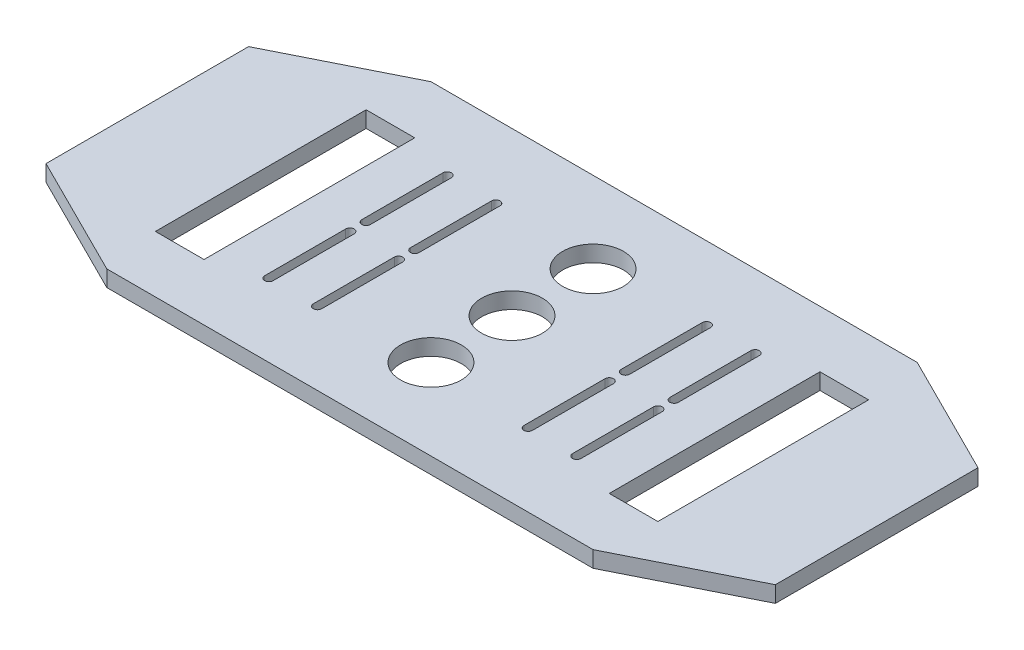
from build123d import *

# Parameters (mm, degrees)
ESQUISSE1_W             = 180
ESQUISSE1_H             = 80
BOSS_EXTRU_1_DEPTH      = 4
ENL_V_MAT_EXTRU_2_DEPTH = 4
ENL_V_MAT_EXTRU_3_DEPTH = 4
ENL_V_MAT_EXTRU_4_REACH = 6
ESQUISSE8_W             = 12
ESQUISSE8_H             = 52
ENL_V_MAT_EXTRU_5_REACH = 6
ESQUISSE9_R             = 7.5


with BuildPart() as part:
    # Esquisse1 → Boss.-Extru.1 (new body)
    with BuildSketch(Plane(origin=(0, 0, 0), x_dir=(1, 0, 0), z_dir=(0, 1, 0))):
        with Locations((90, 40)):
            Rectangle(ESQUISSE1_W, ESQUISSE1_H)
    extrude(amount=BOSS_EXTRU_1_DEPTH)

    # Esquisse2 → Enlèv. mat.-Extru.2 (cut)
    with BuildSketch(Plane(origin=(0, 4, 0), x_dir=(1, 0, 0), z_dir=(0, 1, 0))):
        Polygon((0, 65), (30, 80), (0, 80), align=None)
        Polygon((150, 80), (180, 65), (180, 80), align=None)
        Polygon((150, 0), (180, 15), (180, 0), align=None)
        Polygon((0, 15), (30, 0), (0, 0), align=None)
    extrude(amount=-ENL_V_MAT_EXTRU_2_DEPTH, mode=Mode.SUBTRACT)

    # Esquisse7 → Enlèv. mat.-Extru.3 (cut)
    with BuildSketch(Plane(origin=(0, 4, 0), x_dir=(1, 0, 0), z_dir=(0, 1, 0))):
        with BuildLine():
            Line((62.95, 18), (62.95, 38))
            ThreePointArc((62.95, 38), (64, 39.05), (65.05, 38))
            Line((65.05, 38), (65.05, 18))
            ThreePointArc((65.05, 18), (64, 16.95), (62.95, 18))
        make_face()
        with BuildLine():
            Line((50.95, 18), (50.95, 38))
            ThreePointArc((50.95, 38), (52, 39.05), (53.05, 38))
            Line((53.05, 38), (53.05, 18))
            ThreePointArc((53.05, 18), (52, 16.95), (50.95, 18))
        make_face()
        with BuildLine():
            Line((50.95, 42), (50.95, 62))
            ThreePointArc((50.95, 62), (52, 63.05), (53.05, 62))
            Line((53.05, 62), (53.05, 42))
            ThreePointArc((53.05, 42), (52, 40.95), (50.95, 42))
        make_face()
        with BuildLine():
            Line((62.95, 42), (62.95, 62))
            ThreePointArc((62.95, 62), (64, 63.05), (65.05, 62))
            Line((65.05, 62), (65.05, 42))
            ThreePointArc((65.05, 42), (64, 40.95), (62.95, 42))
        make_face()
        with BuildLine():
            Line((117.05, 42), (117.05, 62))
            ThreePointArc((117.05, 62), (116, 63.05), (114.95, 62))
            Line((114.95, 62), (114.95, 42))
            ThreePointArc((114.95, 42), (116, 40.95), (117.05, 42))
        make_face()
        with BuildLine():
            Line((129.05, 42), (129.05, 62))
            ThreePointArc((129.05, 62), (128, 63.05), (126.95, 62))
            Line((126.95, 62), (126.95, 42))
            ThreePointArc((126.95, 42), (128, 40.95), (129.05, 42))
        make_face()
        with BuildLine():
            Line((129.05, 18), (129.05, 38))
            ThreePointArc((129.05, 38), (128, 39.05), (126.95, 38))
            Line((126.95, 38), (126.95, 18))
            ThreePointArc((126.95, 18), (128, 16.95), (129.05, 18))
        make_face()
        with BuildLine():
            Line((117.05, 18), (117.05, 38))
            ThreePointArc((117.05, 38), (116, 39.05), (114.95, 38))
            Line((114.95, 38), (114.95, 18))
            ThreePointArc((114.95, 18), (116, 16.95), (117.05, 18))
        make_face()
    extrude(amount=-ENL_V_MAT_EXTRU_3_DEPTH, mode=Mode.SUBTRACT)

    # Esquisse8 → Enlèv. mat.-Extru.4 (cut, up to next)
    with BuildSketch(Plane(origin=(0, 4, 0), x_dir=(1, 0, 0), z_dir=(0, 1, 0)), mode=Mode.PRIVATE) as enl_v_mat_extru_4_sk1:
        with Locations((146, 40)):
            Rectangle(ESQUISSE8_W, ESQUISSE8_H)
    enl_v_mat_extru_4_tool1 = extrude(enl_v_mat_extru_4_sk1.sketch, amount=-ENL_V_MAT_EXTRU_4_REACH, mode=Mode.PRIVATE) & part.part
    add(enl_v_mat_extru_4_tool1.solids().sort_by_distance((146, 4, -40))[0], mode=Mode.SUBTRACT)
    # Esquisse8 → Enlèv. mat.-Extru.4 (cut, up to next)
    with BuildSketch(Plane(origin=(0, 4, 0), x_dir=(1, 0, 0), z_dir=(0, 1, 0)), mode=Mode.PRIVATE) as enl_v_mat_extru_4_sk2:
        with Locations((34, 40)):
            Rectangle(ESQUISSE8_W, ESQUISSE8_H)
    enl_v_mat_extru_4_tool2 = extrude(enl_v_mat_extru_4_sk2.sketch, amount=-ENL_V_MAT_EXTRU_4_REACH, mode=Mode.PRIVATE) & part.part
    add(enl_v_mat_extru_4_tool2.solids().sort_by_distance((34, 4, -40))[0], mode=Mode.SUBTRACT)

    # Esquisse9 → Enlèv. mat.-Extru.5 (cut, up to next)
    with BuildSketch(Plane.XZ, mode=Mode.PRIVATE) as enl_v_mat_extru_5_sk1:
        with Locations((90, -60)):
            Circle(ESQUISSE9_R)
    enl_v_mat_extru_5_tool1 = extrude(enl_v_mat_extru_5_sk1.sketch, amount=-ENL_V_MAT_EXTRU_5_REACH, mode=Mode.PRIVATE) & part.part
    add(enl_v_mat_extru_5_tool1.solids().sort_by_distance((90, 0, -60))[0], mode=Mode.SUBTRACT)
    # Esquisse9 → Enlèv. mat.-Extru.5 (cut, up to next)
    with BuildSketch(Plane.XZ, mode=Mode.PRIVATE) as enl_v_mat_extru_5_sk2:
        with Locations((90, -40)):
            Circle(ESQUISSE9_R)
    enl_v_mat_extru_5_tool2 = extrude(enl_v_mat_extru_5_sk2.sketch, amount=-ENL_V_MAT_EXTRU_5_REACH, mode=Mode.PRIVATE) & part.part
    add(enl_v_mat_extru_5_tool2.solids().sort_by_distance((90, 0, -40))[0], mode=Mode.SUBTRACT)
    # Esquisse9 → Enlèv. mat.-Extru.5 (cut, up to next)
    with BuildSketch(Plane.XZ, mode=Mode.PRIVATE) as enl_v_mat_extru_5_sk3:
        with Locations((90, -20)):
            Circle(ESQUISSE9_R)
    enl_v_mat_extru_5_tool3 = extrude(enl_v_mat_extru_5_sk3.sketch, amount=-ENL_V_MAT_EXTRU_5_REACH, mode=Mode.PRIVATE) & part.part
    add(enl_v_mat_extru_5_tool3.solids().sort_by_distance((90, 0, -20))[0], mode=Mode.SUBTRACT)


solid = part.part
